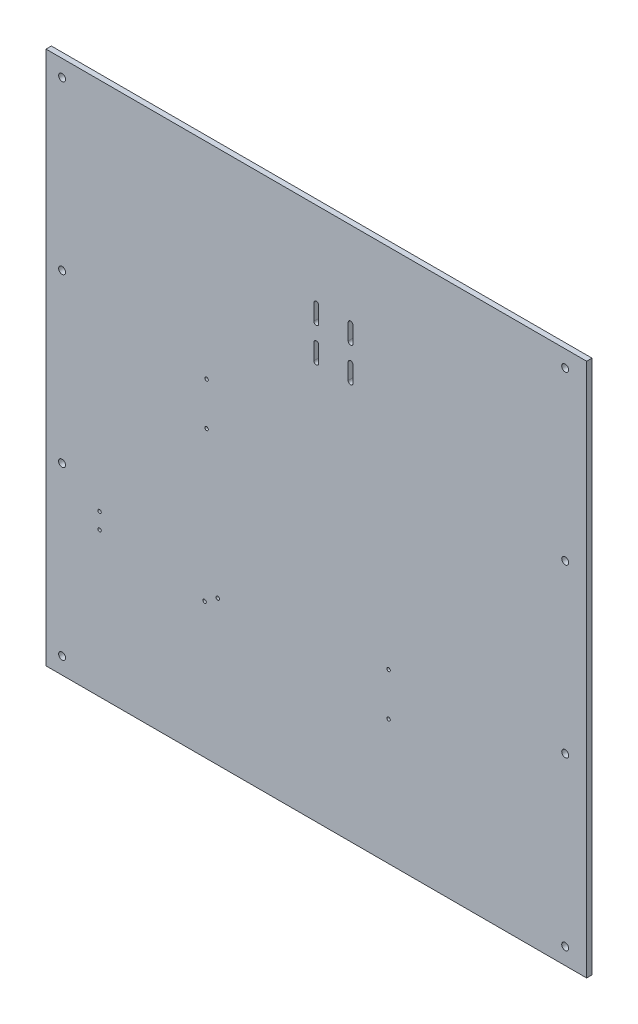
from build123d import *

# Parameters (mm, degrees)
MODEL_W             = 505
MODEL_H             = 499
MODEL_R             = 1.6
MODEL_R_2           = 3.25
BOSS_EXTRUDE1_DEPTH = 5


with BuildPart() as part:
    # Model → Boss-Extrude1 (new body)
    with BuildSketch(Plane.XY):
        with Locations((252.5, 249.5)):
            Rectangle(MODEL_W, MODEL_H)
        with Locations((160.409226252, 134.98839597)):
            Circle(MODEL_R, mode=Mode.SUBTRACT)
        with Locations((50, 135)):
            Circle(MODEL_R, mode=Mode.SUBTRACT)
        with Locations((148.121945588, 126.384749425)):
            Circle(MODEL_R, mode=Mode.SUBTRACT)
        with Locations((50, 150)):
            Circle(MODEL_R, mode=Mode.SUBTRACT)
        with Locations((150, 267)):
            Circle(MODEL_R, mode=Mode.SUBTRACT)
        with Locations((150, 307)):
            Circle(MODEL_R, mode=Mode.SUBTRACT)
        with Locations((320, 117)):
            Circle(MODEL_R, mode=Mode.SUBTRACT)
        with Locations((15, 15.5)):
            Circle(MODEL_R_2, mode=Mode.SUBTRACT)
        with Locations((485, 15.5)):
            Circle(MODEL_R_2, mode=Mode.SUBTRACT)
        with Locations((15, 171.5)):
            Circle(MODEL_R_2, mode=Mode.SUBTRACT)
        with Locations((485, 171.5)):
            Circle(MODEL_R_2, mode=Mode.SUBTRACT)
        with Locations((15, 327.5)):
            Circle(MODEL_R_2, mode=Mode.SUBTRACT)
        with Locations((485, 327.5)):
            Circle(MODEL_R_2, mode=Mode.SUBTRACT)
        with Locations((15, 483.5)):
            Circle(MODEL_R_2, mode=Mode.SUBTRACT)
        with Locations((485, 483.5)):
            Circle(MODEL_R_2, mode=Mode.SUBTRACT)
        with Locations((320, 157)):
            Circle(MODEL_R, mode=Mode.SUBTRACT)
        with BuildLine():
            Line((250.25, 404), (250.25, 419))
            ThreePointArc((250.25, 419), (252.5, 421.25), (254.75, 419))
            Line((254.75, 419), (254.75, 404))
            ThreePointArc((254.75, 404), (252.5, 401.75), (250.25, 404))
        make_face(mode=Mode.SUBTRACT)
        with BuildLine():
            Line((254.75, 387), (254.75, 372))
            ThreePointArc((254.75, 372), (252.5, 369.75), (250.25, 372))
            Line((250.25, 372), (250.25, 387))
            ThreePointArc((250.25, 387), (252.5, 389.25), (254.75, 387))
        make_face(mode=Mode.SUBTRACT)
        with BuildLine():
            Line((286.75, 387), (286.75, 372))
            ThreePointArc((286.75, 372), (284.5, 369.75), (282.25, 372))
            Line((282.25, 372), (282.25, 387))
            ThreePointArc((282.25, 387), (284.5, 389.25), (286.75, 387))
        make_face(mode=Mode.SUBTRACT)
        with BuildLine():
            Line((286.75, 419), (286.75, 404))
            ThreePointArc((286.75, 404), (284.5, 401.75), (282.25, 404))
            Line((282.25, 404), (282.25, 419))
            ThreePointArc((282.25, 419), (284.5, 421.25), (286.75, 419))
        make_face(mode=Mode.SUBTRACT)
    extrude(amount=BOSS_EXTRUDE1_DEPTH)


solid = part.part
